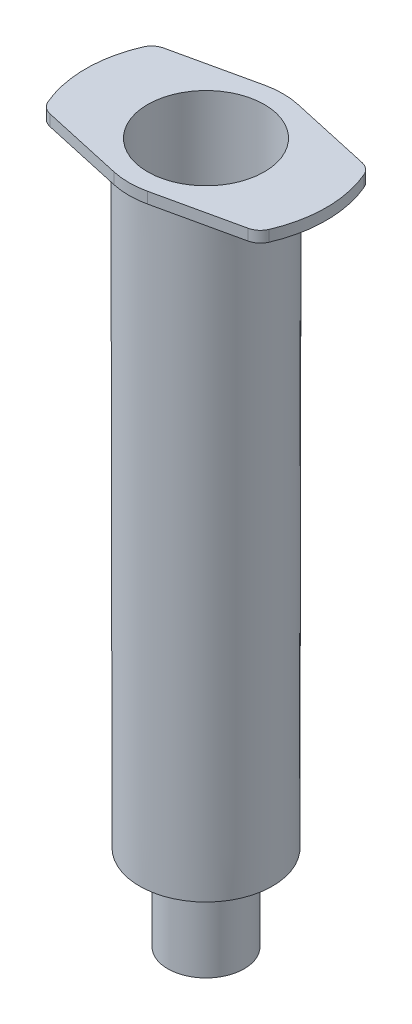
from build123d import *

# Parameters (mm, degrees)
BOSS_EXTRUDE2_DEPTH = 1.37
FILLET1_R           = 2
CUT_EXTRUDE1_REACH  = 88.37
SKETCH3_R           = 7.2


with BuildPart() as part:
    # Sketch1 → Revolve1 (revolve)
    with BuildSketch(Plane.XY):
        Polygon((8.3, 86.37), (8.2, 10.576282817), (4.71, 8.87), (4.71, 0), (3.96, 0), (3.96, 4.391129032), (2, 4.391129032), (2, 0), (1, 0), (1, 8.169274748), (7.2, 11.200493506), (7.2, 86.37), align=None)
    revolve(axis=Axis((0, 0, 0), (0, 1, 0)))

    # Sketch2 → Boss-Extrude2 (add)
    with BuildSketch(Plane(origin=(0, 86.37, 0), x_dir=(1, 0, 0), z_dir=(0, 1, 0))):
        with BuildLine():
            Line((2.056176332, 9.274812068), (13.180263935, 6.808661219))
            ThreePointArc((13.180263935, 6.808661219), (14.835, 0), (13.180263935, -6.808661219))
            Line((13.180263935, -6.808661219), (2.056176332, -9.274812068))
            ThreePointArc((2.056176332, -9.274812068), (0, -9.5), (-2.056176332, -9.274812068))
            Line((-2.056176332, -9.274812068), (-13.180263935, -6.808661219))
            ThreePointArc((-13.180263935, -6.808661219), (-14.835, 0), (-13.180263935, 6.808661219))
            Line((-13.180263935, 6.808661219), (-2.056176332, 9.274812068))
            ThreePointArc((-2.056176332, 9.274812068), (0, 9.5), (2.056176332, 9.274812068))
        make_face()
    extrude(amount=-BOSS_EXTRUDE2_DEPTH)

    # Fillet1
    fillet1_edges = [part.edges().sort_by_distance(p)[0] for p in [
        (13.180263935, 85.685, -6.808661219),
        (13.180263935, 85.685, 6.808661219),
        (-13.180263935, 85.685, 6.808661219),
        (-13.180263935, 85.685, -6.808661219),
    ]]
    fillet(fillet1_edges, radius=FILLET1_R)

    # Sketch3 → Cut-Extrude1 (cut, up to next)
    with BuildSketch(Plane(origin=(0, 86.37, 0), x_dir=(1, 0, 0), z_dir=(0, 1, 0)), mode=Mode.PRIVATE) as cut_extrude1_sk1:
        Circle(SKETCH3_R)
    cut_extrude1_tool1 = extrude(cut_extrude1_sk1.sketch, amount=-CUT_EXTRUDE1_REACH, mode=Mode.PRIVATE) & part.part
    add(cut_extrude1_tool1.solids().sort_by_distance((0, 86.37, 0))[0], mode=Mode.SUBTRACT)


solid = part.part
